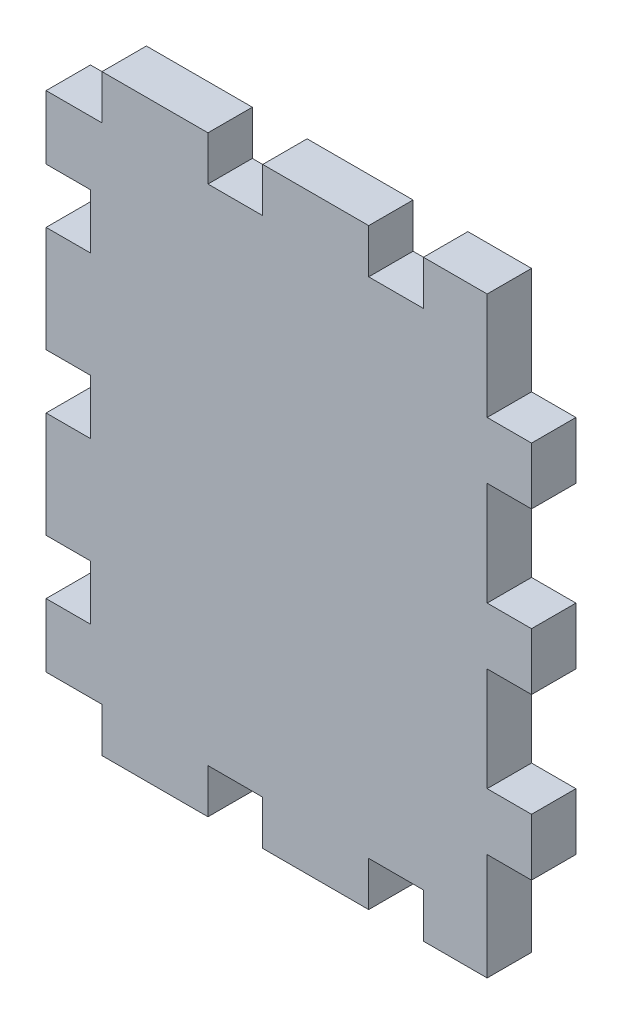
from build123d import *

# Parameters (mm, degrees)
BOSS_EXTRUDE1_DEPTH = 3.175
SKETCH4_W           = 3.175
SKETCH4_H           = 4
CUT_EXTRUDE1_DEPTH  = 10
BOSS_EXTRUDE2_DEPTH = 3.175


with BuildPart() as part:
    # Sketch2 → Boss-Extrude1 (new body)
    with BuildSketch(Plane.XY):
        Polygon((-2, 17.975), (-2, 21.15), (-9.5, 21.15), (-9.5, 17.975), (-13.5, 17.975), (-13.5, 21.15), (-21.15, 21.15), (-21.15, 13.5), (-17.975, 13.5), (-17.975, 9.5), (-21.15, 9.5), (-21.15, 2), (-17.975, 2), (-17.975, -2), (-21.15, -2), (-21.15, -9.5), (-17.975, -9.5), (-17.975, -13.5), (-21.15, -13.5), (-21.15, -21.15), (-13.5, -21.15), (-13.5, -17.975), (-9.5, -17.975), (-9.5, -21.15), (-2, -21.15), (-2, -17.975), (2, -17.975), (2, -21.15), (9.5, -21.15), (9.5, -17.975), (13.5, -17.975), (13.5, -21.15), (17.975, -21.15), (17.975, -13.5), (21.15, -13.5), (21.15, -9.5), (17.975, -9.5), (17.975, -2), (21.15, -2), (21.15, 2), (17.975, 2), (17.975, 9.5), (21.15, 9.5), (21.15, 13.5), (17.975, 13.5), (17.975, 21.15), (13.5, 21.15), (13.5, 17.975), (9.5, 17.975), (9.5, 21.15), (2, 21.15), (2, 17.975), align=None)
    extrude(amount=BOSS_EXTRUDE1_DEPTH)

    # Sketch4 → Cut-Extrude1 (cut)
    with BuildSketch(Plane.XY.offset(3.175)):
        Polygon((-13.5, 13.5), (-13.5, 17.975), (-13.5, 21.15), (-21.15, 21.15), (-21.15, -21.15), (-13.5, -21.15), (-13.5, -17.975), (-13.5, -13.5), (-13.5, -9.5), (-13.5, -2), (-13.5, 2), (-13.5, 9.5), align=None)
        with Locations((-11.9125, 11.5)):
            Rectangle(SKETCH4_W, SKETCH4_H)
        with Locations((-11.9125, 0)):
            Rectangle(SKETCH4_W, SKETCH4_H)
        with Locations((-11.9125, -11.5)):
            Rectangle(SKETCH4_W, SKETCH4_H)
    extrude(amount=-CUT_EXTRUDE1_DEPTH, mode=Mode.SUBTRACT)

    # Sketch3 → Boss-Extrude2 (add)
    with BuildSketch(Plane.XY.offset(3.175)):
        Polygon((-13.54064, 18.01564), (-13.54064, 13.45936), (-10.36564, 13.45936), (-10.36564, 9.54064), (-13.54064, 9.54064), (-13.54064, 1.95936), (-10.36564, 1.95936), (-10.36564, -1.95936), (-13.54064, -1.95936), (-13.54064, -9.54064), (-10.36564, -9.54064), (-10.36564, -13.45936), (-13.54064, -13.45936), (-13.54064, -18.01564), (-9.54064, -18.01564), (-9.54064, -21.19064), (-1.95936, -21.19064), (-1.95936, -18.01564), (1.95936, -18.01564), (1.95936, -21.19064), (9.54064, -21.19064), (9.54064, -18.01564), (13.45936, -18.01564), (13.45936, -21.19064), (18.01564, -21.19064), (18.01564, -13.54064), (21.19064, -13.54064), (21.19064, -9.45936), (18.01564, -9.45936), (18.01564, -2.04064), (21.19064, -2.04064), (21.19064, 2.04064), (18.01564, 2.04064), (18.01564, 9.45936), (21.19064, 9.45936), (21.19064, 13.54064), (18.01564, 13.54064), (18.01564, 21.19064), (13.45936, 21.19064), (13.45936, 18.01564), (9.54064, 18.01564), (9.54064, 21.19064), (1.95936, 21.19064), (1.95936, 18.01564), (-1.95936, 18.01564), (-1.95936, 21.19064), (-9.54064, 21.19064), (-9.54064, 18.01564), align=None)
    extrude(amount=-BOSS_EXTRUDE2_DEPTH)


solid = part.part
